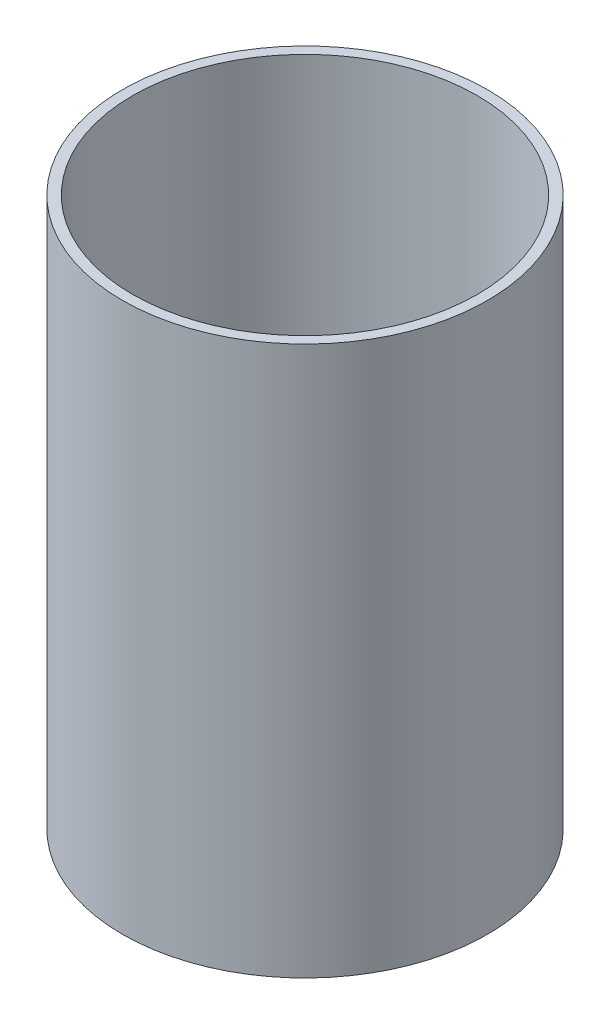
from build123d import *

# Parameters (mm, degrees)
SKETCH1_R           = 25.3365
SKETCH1_R_2         = 23.9141
BOSS_EXTRUDE1_DEPTH = 76.2


with BuildPart() as part:
    # Sketch1 → Boss-Extrude1 (new body)
    with BuildSketch(Plane(origin=(0, 0, 0), x_dir=(1, 0, 0), z_dir=(0, 1, 0))):
        Circle(SKETCH1_R)
        Circle(SKETCH1_R_2, mode=Mode.SUBTRACT)
    extrude(amount=BOSS_EXTRUDE1_DEPTH)


solid = part.part
